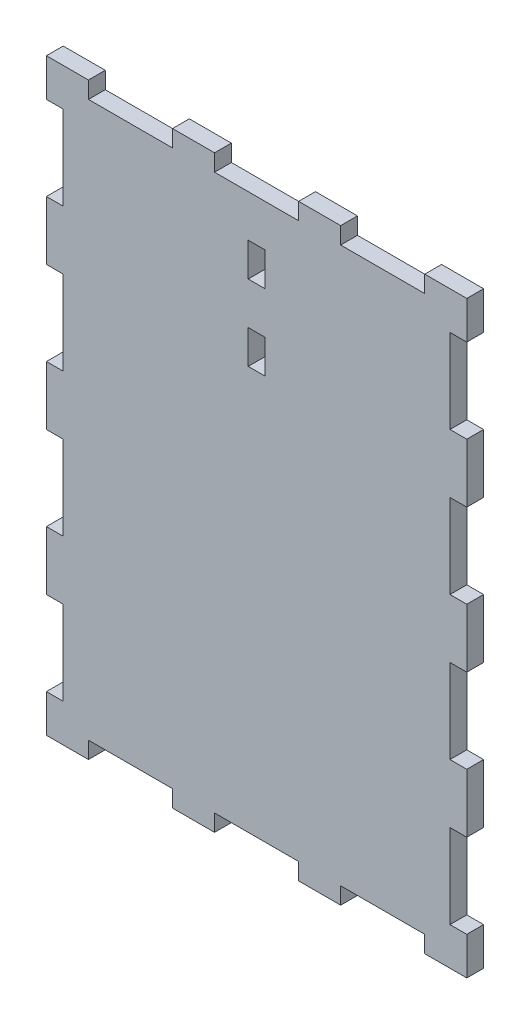
from build123d import *

# Parameters (mm, degrees)
SKETCH2_W           = 127
SKETCH2_H           = 177.8
BOSS_EXTRUDE2_DEPTH = 5.08
SKETCH3_W           = 5.08
SKETCH3_H           = 25.4
CUT_EXTRUDE1_DEPTH  = 5.08
LPATTERN1_COUNT     = 5
LPATTERN1_PITCH     = 43.18
SKETCH4_W           = 5.08
SKETCH4_H           = 25.4
CUT_EXTRUDE2_DEPTH  = 5.08
LPATTERN2_COUNT     = 4
LPATTERN2_PITCH     = 43.18
SKETCH5_W           = 25.4
SKETCH5_H           = 5.08
CUT_EXTRUDE3_DEPTH  = 5.08
LPATTERN3_COUNT     = 3
LPATTERN3_PITCH     = 38.1
SKETCH6_W           = 25.4
SKETCH6_H           = 5.08
CUT_EXTRUDE4_DEPTH  = 5.08
LPATTERN4_COUNT     = 3
LPATTERN4_PITCH     = 38.1
SKETCH7_W           = 5.08
SKETCH7_H           = 10.16
CUT_EXTRUDE5_DEPTH  = 5.08


with BuildPart() as part:
    # Sketch2 → Boss-Extrude2 (new body)
    with BuildSketch(Plane.XY):
        with Locations((63.5, -88.9)):
            Rectangle(SKETCH2_W, SKETCH2_H)
    extrude(amount=BOSS_EXTRUDE2_DEPTH)

    # Sketch3 → Cut-Extrude1 (cut)
    with BuildSketch(Plane(origin=(0, 0, 0), x_dir=(-1, 0, 0), z_dir=(0, 0, -1))):
        with Locations((-124.46, -153.67)):
            Rectangle(SKETCH3_W, SKETCH3_H)
    cut_extrude1 = extrude(amount=-CUT_EXTRUDE1_DEPTH, mode=Mode.SUBTRACT)

    # LPattern1: Cut-Extrude1 ×5
    with Locations(*[(0, i * LPATTERN1_PITCH, 0) for i in range(1, LPATTERN1_COUNT)]):
        add(cut_extrude1, mode=Mode.SUBTRACT)

    # Sketch4 → Cut-Extrude2 (cut)
    with BuildSketch(Plane(origin=(0, 0, 0), x_dir=(-1, 0, 0), z_dir=(0, 0, -1))):
        with Locations((-2.54, -153.67)):
            Rectangle(SKETCH4_W, SKETCH4_H)
    cut_extrude2 = extrude(amount=-CUT_EXTRUDE2_DEPTH, mode=Mode.SUBTRACT)

    # LPattern2: Cut-Extrude2 ×4
    with Locations(*[(0, i * LPATTERN2_PITCH, 0) for i in range(1, LPATTERN2_COUNT)]):
        add(cut_extrude2, mode=Mode.SUBTRACT)

    # Sketch5 → Cut-Extrude3 (cut)
    with BuildSketch(Plane(origin=(0, 0, 0), x_dir=(-1, 0, 0), z_dir=(0, 0, -1))):
        with Locations((-101.6, -175.26)):
            Rectangle(SKETCH5_W, SKETCH5_H)
    cut_extrude3 = extrude(amount=-CUT_EXTRUDE3_DEPTH, mode=Mode.SUBTRACT)

    # LPattern3: Cut-Extrude3 ×3
    with Locations(*[(-i * LPATTERN3_PITCH, 0, 0) for i in range(1, LPATTERN3_COUNT)]):
        add(cut_extrude3, mode=Mode.SUBTRACT)

    # Sketch6 → Cut-Extrude4 (cut)
    with BuildSketch(Plane(origin=(0, 0, 0), x_dir=(-1, 0, 0), z_dir=(0, 0, -1))):
        with Locations((-25.4, -2.54)):
            Rectangle(SKETCH6_W, SKETCH6_H)
    cut_extrude4 = extrude(amount=-CUT_EXTRUDE4_DEPTH, mode=Mode.SUBTRACT)

    # LPattern4: Cut-Extrude4 ×3
    with Locations(*[(i * LPATTERN4_PITCH, 0, 0) for i in range(1, LPATTERN4_COUNT)]):
        add(cut_extrude4, mode=Mode.SUBTRACT)

    # Sketch7 → Cut-Extrude5 (cut)
    with BuildSketch(Plane.XY.offset(5.08)):
        with Locations((63.5, -22.86)):
            Rectangle(SKETCH7_W, SKETCH7_H)
        with Locations((63.5, -45.72)):
            Rectangle(SKETCH7_W, SKETCH7_H)
    extrude(amount=-CUT_EXTRUDE5_DEPTH, mode=Mode.SUBTRACT)


solid = part.part
